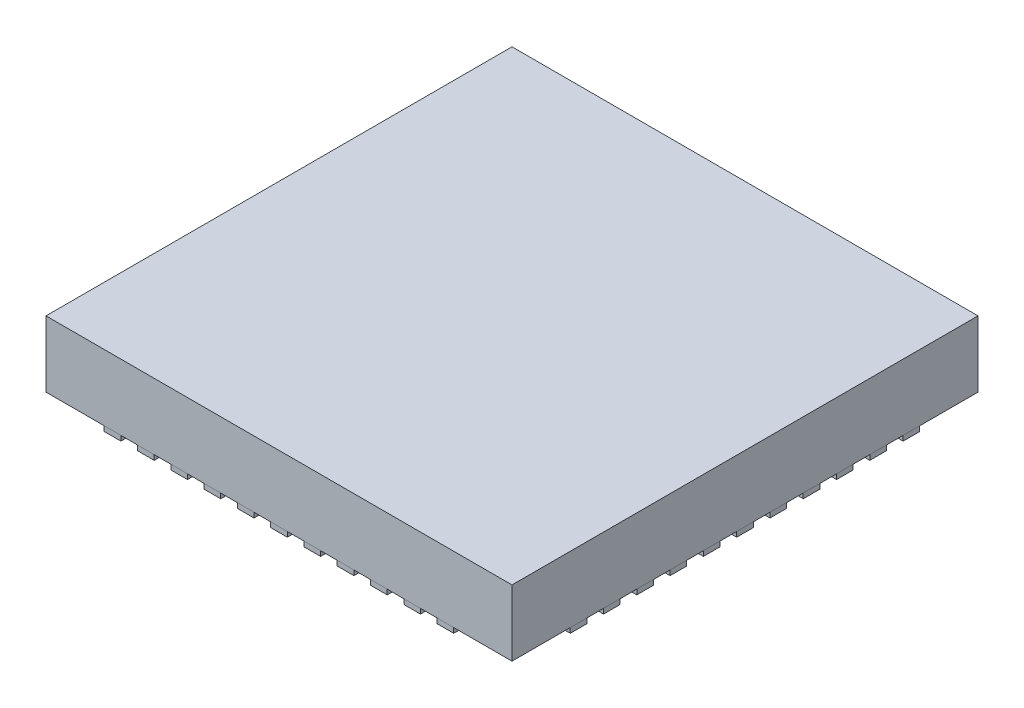
from build123d import *

# Parameters (mm, degrees)
SKETCH2_W              = 7
SKETCH2_H              = 7
BOSS_EXTRUDE1_DEPTH    = 0.9925
SKETCH3_W              = 0.25
SKETCH3_H              = 0.55
BOSS_EXTRUDE2_DEPTH    = 0.075
BOSS_EXTRUDE2_2_DEPTH  = 0.075
BOSS_EXTRUDE2_3_DEPTH  = 0.075
BOSS_EXTRUDE2_4_DEPTH  = 0.075
BOSS_EXTRUDE2_5_DEPTH  = 0.075
BOSS_EXTRUDE2_6_DEPTH  = 0.075
SKETCH3_W_2            = 0.55
SKETCH3_H_2            = 0.25
BOSS_EXTRUDE2_7_DEPTH  = 0.075
BOSS_EXTRUDE2_8_DEPTH  = 0.075
BOSS_EXTRUDE2_9_DEPTH  = 0.075
BOSS_EXTRUDE2_10_DEPTH = 0.075
BOSS_EXTRUDE2_11_DEPTH = 0.075
BOSS_EXTRUDE2_12_DEPTH = 0.075
BOSS_EXTRUDE2_13_DEPTH = 0.075
BOSS_EXTRUDE2_14_DEPTH = 0.075
BOSS_EXTRUDE2_15_DEPTH = 0.075
BOSS_EXTRUDE2_16_DEPTH = 0.075
BOSS_EXTRUDE2_17_DEPTH = 0.075
BOSS_EXTRUDE2_18_DEPTH = 0.075
BOSS_EXTRUDE2_19_DEPTH = 0.075
BOSS_EXTRUDE2_20_DEPTH = 0.075
BOSS_EXTRUDE2_21_DEPTH = 0.075
BOSS_EXTRUDE2_22_DEPTH = 0.075
BOSS_EXTRUDE2_23_DEPTH = 0.075
BOSS_EXTRUDE2_24_DEPTH = 0.075
BOSS_EXTRUDE2_25_DEPTH = 0.075
BOSS_EXTRUDE2_26_DEPTH = 0.075
BOSS_EXTRUDE2_27_DEPTH = 0.075
BOSS_EXTRUDE2_28_DEPTH = 0.075
BOSS_EXTRUDE2_29_DEPTH = 0.075
BOSS_EXTRUDE2_30_DEPTH = 0.075
BOSS_EXTRUDE2_31_DEPTH = 0.075
BOSS_EXTRUDE2_32_DEPTH = 0.075
BOSS_EXTRUDE2_33_DEPTH = 0.075
BOSS_EXTRUDE2_34_DEPTH = 0.075
BOSS_EXTRUDE2_35_DEPTH = 0.075
BOSS_EXTRUDE2_36_DEPTH = 0.075
BOSS_EXTRUDE2_37_DEPTH = 0.075
BOSS_EXTRUDE2_38_DEPTH = 0.075
BOSS_EXTRUDE2_39_DEPTH = 0.075
BOSS_EXTRUDE2_40_DEPTH = 0.075
BOSS_EXTRUDE2_41_DEPTH = 0.075
BOSS_EXTRUDE2_42_DEPTH = 0.075
BOSS_EXTRUDE2_43_DEPTH = 0.075
BOSS_EXTRUDE2_44_DEPTH = 0.075


with BuildPart() as part:
    # Sketch2 → Boss-Extrude1 (new body)
    with BuildSketch(Plane(origin=(0, 0, 0), x_dir=(1, 0, 0), z_dir=(0, 1, 0))):
        Rectangle(SKETCH2_W, SKETCH2_H)
    extrude(amount=BOSS_EXTRUDE1_DEPTH)


with BuildPart() as body_2:
    # Sketch3 → Boss-Extrude2 (new body)
    with BuildSketch(Plane.XZ):
        with Locations((-0.5, 3.225)):
            Rectangle(SKETCH3_W, SKETCH3_H)
    extrude(amount=BOSS_EXTRUDE2_DEPTH)


with BuildPart() as body_3:
    # Sketch3 → Boss-Extrude2 2 (new body)
    with BuildSketch(Plane.XZ):
        with Locations((0, 3.225)):
            Rectangle(SKETCH3_W, SKETCH3_H)
    extrude(amount=BOSS_EXTRUDE2_2_DEPTH)


with BuildPart() as body_4:
    # Sketch3 → Boss-Extrude2 3 (new body)
    with BuildSketch(Plane.XZ):
        with Locations((-1, 3.225)):
            Rectangle(SKETCH3_W, SKETCH3_H)
    extrude(amount=BOSS_EXTRUDE2_3_DEPTH)


with BuildPart() as body_5:
    # Sketch3 → Boss-Extrude2 4 (new body)
    with BuildSketch(Plane.XZ):
        with Locations((-1.5, 3.225)):
            Rectangle(SKETCH3_W, SKETCH3_H)
    extrude(amount=BOSS_EXTRUDE2_4_DEPTH)


with BuildPart() as body_6:
    # Sketch3 → Boss-Extrude2 5 (new body)
    with BuildSketch(Plane.XZ):
        with Locations((-2, 3.225)):
            Rectangle(SKETCH3_W, SKETCH3_H)
    extrude(amount=BOSS_EXTRUDE2_5_DEPTH)


with BuildPart() as body_7:
    # Sketch3 → Boss-Extrude2 6 (new body)
    with BuildSketch(Plane.XZ):
        with Locations((-2.5, 3.225)):
            Rectangle(SKETCH3_W, SKETCH3_H)
    extrude(amount=BOSS_EXTRUDE2_6_DEPTH)


with BuildPart() as body_8:
    # Sketch3 → Boss-Extrude2 7 (new body)
    with BuildSketch(Plane.XZ):
        with Locations((-3.225, -0.5)):
            Rectangle(SKETCH3_W_2, SKETCH3_H_2)
    extrude(amount=BOSS_EXTRUDE2_7_DEPTH)


with BuildPart() as body_9:
    # Sketch3 → Boss-Extrude2 8 (new body)
    with BuildSketch(Plane.XZ):
        with Locations((-3.225, 0)):
            Rectangle(SKETCH3_W_2, SKETCH3_H_2)
    extrude(amount=BOSS_EXTRUDE2_8_DEPTH)


with BuildPart() as body_10:
    # Sketch3 → Boss-Extrude2 9 (new body)
    with BuildSketch(Plane.XZ):
        with Locations((-3.225, 2.5)):
            Rectangle(SKETCH3_W_2, SKETCH3_H_2)
    extrude(amount=BOSS_EXTRUDE2_9_DEPTH)


with BuildPart() as body_11:
    # Sketch3 → Boss-Extrude2 10 (new body)
    with BuildSketch(Plane.XZ):
        with Locations((-3.225, 2)):
            Rectangle(SKETCH3_W_2, SKETCH3_H_2)
    extrude(amount=BOSS_EXTRUDE2_10_DEPTH)


with BuildPart() as body_12:
    # Sketch3 → Boss-Extrude2 11 (new body)
    with BuildSketch(Plane.XZ):
        with Locations((-3.225, 1.5)):
            Rectangle(SKETCH3_W_2, SKETCH3_H_2)
    extrude(amount=BOSS_EXTRUDE2_11_DEPTH)


with BuildPart() as body_13:
    # Sketch3 → Boss-Extrude2 12 (new body)
    with BuildSketch(Plane.XZ):
        with Locations((-3.225, 1)):
            Rectangle(SKETCH3_W_2, SKETCH3_H_2)
    extrude(amount=BOSS_EXTRUDE2_12_DEPTH)


with BuildPart() as body_14:
    # Sketch3 → Boss-Extrude2 13 (new body)
    with BuildSketch(Plane.XZ):
        with Locations((-3.225, 0.5)):
            Rectangle(SKETCH3_W_2, SKETCH3_H_2)
    extrude(amount=BOSS_EXTRUDE2_13_DEPTH)


with BuildPart() as body_15:
    # Sketch3 → Boss-Extrude2 14 (new body)
    with BuildSketch(Plane.XZ):
        with Locations((2.5, 3.225)):
            Rectangle(SKETCH3_W, SKETCH3_H)
    extrude(amount=BOSS_EXTRUDE2_14_DEPTH)


with BuildPart() as body_16:
    # Sketch3 → Boss-Extrude2 15 (new body)
    with BuildSketch(Plane.XZ):
        with Locations((2, 3.225)):
            Rectangle(SKETCH3_W, SKETCH3_H)
    extrude(amount=BOSS_EXTRUDE2_15_DEPTH)


with BuildPart() as body_17:
    # Sketch3 → Boss-Extrude2 16 (new body)
    with BuildSketch(Plane.XZ):
        with Locations((1.5, 3.225)):
            Rectangle(SKETCH3_W, SKETCH3_H)
    extrude(amount=BOSS_EXTRUDE2_16_DEPTH)


with BuildPart() as body_18:
    # Sketch3 → Boss-Extrude2 17 (new body)
    with BuildSketch(Plane.XZ):
        with Locations((1, 3.225)):
            Rectangle(SKETCH3_W, SKETCH3_H)
    extrude(amount=BOSS_EXTRUDE2_17_DEPTH)


with BuildPart() as body_19:
    # Sketch3 → Boss-Extrude2 18 (new body)
    with BuildSketch(Plane.XZ):
        with Locations((0.5, 3.225)):
            Rectangle(SKETCH3_W, SKETCH3_H)
    extrude(amount=BOSS_EXTRUDE2_18_DEPTH)


with BuildPart() as body_20:
    # Sketch3 → Boss-Extrude2 19 (new body)
    with BuildSketch(Plane.XZ):
        with Locations((-3.225, -1)):
            Rectangle(SKETCH3_W_2, SKETCH3_H_2)
    extrude(amount=BOSS_EXTRUDE2_19_DEPTH)


with BuildPart() as body_21:
    # Sketch3 → Boss-Extrude2 20 (new body)
    with BuildSketch(Plane.XZ):
        with Locations((-3.225, -1.5)):
            Rectangle(SKETCH3_W_2, SKETCH3_H_2)
    extrude(amount=BOSS_EXTRUDE2_20_DEPTH)


with BuildPart() as body_22:
    # Sketch3 → Boss-Extrude2 21 (new body)
    with BuildSketch(Plane.XZ):
        with Locations((-3.225, -2)):
            Rectangle(SKETCH3_W_2, SKETCH3_H_2)
    extrude(amount=BOSS_EXTRUDE2_21_DEPTH)


with BuildPart() as body_23:
    # Sketch3 → Boss-Extrude2 22 (new body)
    with BuildSketch(Plane.XZ):
        with Locations((-3.225, -2.5)):
            Rectangle(SKETCH3_W_2, SKETCH3_H_2)
    extrude(amount=BOSS_EXTRUDE2_22_DEPTH)


with BuildPart() as body_24:
    # Sketch3 → Boss-Extrude2 23 (new body)
    with BuildSketch(Plane.XZ):
        with Locations((3.225, 0)):
            Rectangle(SKETCH3_W_2, SKETCH3_H_2)
    extrude(amount=BOSS_EXTRUDE2_23_DEPTH)


with BuildPart() as body_25:
    # Sketch3 → Boss-Extrude2 24 (new body)
    with BuildSketch(Plane.XZ):
        with Locations((3.225, -2.5)):
            Rectangle(SKETCH3_W_2, SKETCH3_H_2)
    extrude(amount=BOSS_EXTRUDE2_24_DEPTH)


with BuildPart() as body_26:
    # Sketch3 → Boss-Extrude2 25 (new body)
    with BuildSketch(Plane.XZ):
        with Locations((3.225, -2)):
            Rectangle(SKETCH3_W_2, SKETCH3_H_2)
    extrude(amount=BOSS_EXTRUDE2_25_DEPTH)


with BuildPart() as body_27:
    # Sketch3 → Boss-Extrude2 26 (new body)
    with BuildSketch(Plane.XZ):
        with Locations((3.225, -1.5)):
            Rectangle(SKETCH3_W_2, SKETCH3_H_2)
    extrude(amount=BOSS_EXTRUDE2_26_DEPTH)


with BuildPart() as body_28:
    # Sketch3 → Boss-Extrude2 27 (new body)
    with BuildSketch(Plane.XZ):
        with Locations((3.225, -1)):
            Rectangle(SKETCH3_W_2, SKETCH3_H_2)
    extrude(amount=BOSS_EXTRUDE2_27_DEPTH)


with BuildPart() as body_29:
    # Sketch3 → Boss-Extrude2 28 (new body)
    with BuildSketch(Plane.XZ):
        with Locations((3.225, -0.5)):
            Rectangle(SKETCH3_W_2, SKETCH3_H_2)
    extrude(amount=BOSS_EXTRUDE2_28_DEPTH)


with BuildPart() as body_30:
    # Sketch3 → Boss-Extrude2 29 (new body)
    with BuildSketch(Plane.XZ):
        with Locations((3.225, 0.5)):
            Rectangle(SKETCH3_W_2, SKETCH3_H_2)
    extrude(amount=BOSS_EXTRUDE2_29_DEPTH)


with BuildPart() as body_31:
    # Sketch3 → Boss-Extrude2 30 (new body)
    with BuildSketch(Plane.XZ):
        with Locations((3.225, 1)):
            Rectangle(SKETCH3_W_2, SKETCH3_H_2)
    extrude(amount=BOSS_EXTRUDE2_30_DEPTH)


with BuildPart() as body_32:
    # Sketch3 → Boss-Extrude2 31 (new body)
    with BuildSketch(Plane.XZ):
        with Locations((3.225, 1.5)):
            Rectangle(SKETCH3_W_2, SKETCH3_H_2)
    extrude(amount=BOSS_EXTRUDE2_31_DEPTH)


with BuildPart() as body_33:
    # Sketch3 → Boss-Extrude2 32 (new body)
    with BuildSketch(Plane.XZ):
        with Locations((3.225, 2)):
            Rectangle(SKETCH3_W_2, SKETCH3_H_2)
    extrude(amount=BOSS_EXTRUDE2_32_DEPTH)


with BuildPart() as body_34:
    # Sketch3 → Boss-Extrude2 33 (new body)
    with BuildSketch(Plane.XZ):
        with Locations((3.225, 2.5)):
            Rectangle(SKETCH3_W_2, SKETCH3_H_2)
    extrude(amount=BOSS_EXTRUDE2_33_DEPTH)


with BuildPart() as body_35:
    # Sketch3 → Boss-Extrude2 34 (new body)
    with BuildSketch(Plane.XZ):
        with Locations((0, -3.225)):
            Rectangle(SKETCH3_W, SKETCH3_H)
    extrude(amount=BOSS_EXTRUDE2_34_DEPTH)


with BuildPart() as body_36:
    # Sketch3 → Boss-Extrude2 35 (new body)
    with BuildSketch(Plane.XZ):
        with Locations((0.5, -3.225)):
            Rectangle(SKETCH3_W, SKETCH3_H)
    extrude(amount=BOSS_EXTRUDE2_35_DEPTH)


with BuildPart() as body_37:
    # Sketch3 → Boss-Extrude2 36 (new body)
    with BuildSketch(Plane.XZ):
        with Locations((1, -3.225)):
            Rectangle(SKETCH3_W, SKETCH3_H)
    extrude(amount=BOSS_EXTRUDE2_36_DEPTH)


with BuildPart() as body_38:
    # Sketch3 → Boss-Extrude2 37 (new body)
    with BuildSketch(Plane.XZ):
        with Locations((1.5, -3.225)):
            Rectangle(SKETCH3_W, SKETCH3_H)
    extrude(amount=BOSS_EXTRUDE2_37_DEPTH)


with BuildPart() as body_39:
    # Sketch3 → Boss-Extrude2 38 (new body)
    with BuildSketch(Plane.XZ):
        with Locations((2, -3.225)):
            Rectangle(SKETCH3_W, SKETCH3_H)
    extrude(amount=BOSS_EXTRUDE2_38_DEPTH)


with BuildPart() as body_40:
    # Sketch3 → Boss-Extrude2 39 (new body)
    with BuildSketch(Plane.XZ):
        with Locations((2.5, -3.225)):
            Rectangle(SKETCH3_W, SKETCH3_H)
    extrude(amount=BOSS_EXTRUDE2_39_DEPTH)


with BuildPart() as body_41:
    # Sketch3 → Boss-Extrude2 40 (new body)
    with BuildSketch(Plane.XZ):
        with Locations((-2.5, -3.225)):
            Rectangle(SKETCH3_W, SKETCH3_H)
    extrude(amount=BOSS_EXTRUDE2_40_DEPTH)


with BuildPart() as body_42:
    # Sketch3 → Boss-Extrude2 41 (new body)
    with BuildSketch(Plane.XZ):
        with Locations((-2, -3.225)):
            Rectangle(SKETCH3_W, SKETCH3_H)
    extrude(amount=BOSS_EXTRUDE2_41_DEPTH)


with BuildPart() as body_43:
    # Sketch3 → Boss-Extrude2 42 (new body)
    with BuildSketch(Plane.XZ):
        with Locations((-1.5, -3.225)):
            Rectangle(SKETCH3_W, SKETCH3_H)
    extrude(amount=BOSS_EXTRUDE2_42_DEPTH)


with BuildPart() as body_44:
    # Sketch3 → Boss-Extrude2 43 (new body)
    with BuildSketch(Plane.XZ):
        with Locations((-1, -3.225)):
            Rectangle(SKETCH3_W, SKETCH3_H)
    extrude(amount=BOSS_EXTRUDE2_43_DEPTH)


with BuildPart() as body_45:
    # Sketch3 → Boss-Extrude2 44 (new body)
    with BuildSketch(Plane.XZ):
        with Locations((-0.5, -3.225)):
            Rectangle(SKETCH3_W, SKETCH3_H)
    extrude(amount=BOSS_EXTRUDE2_44_DEPTH)


solid = Compound([part.part, body_2.part, body_3.part, body_4.part, body_5.part, body_6.part, body_7.part, body_8.part, body_9.part, body_10.part, body_11.part, body_12.part, body_13.part, body_14.part, body_15.part, body_16.part, body_17.part, body_18.part, body_19.part, body_20.part, body_21.part, body_22.part, body_23.part, body_24.part, body_25.part, body_26.part, body_27.part, body_28.part, body_29.part, body_30.part, body_31.part, body_32.part, body_33.part, body_34.part, body_35.part, body_36.part, body_37.part, body_38.part, body_39.part, body_40.part, body_41.part, body_42.part, body_43.part, body_44.part, body_45.part])
